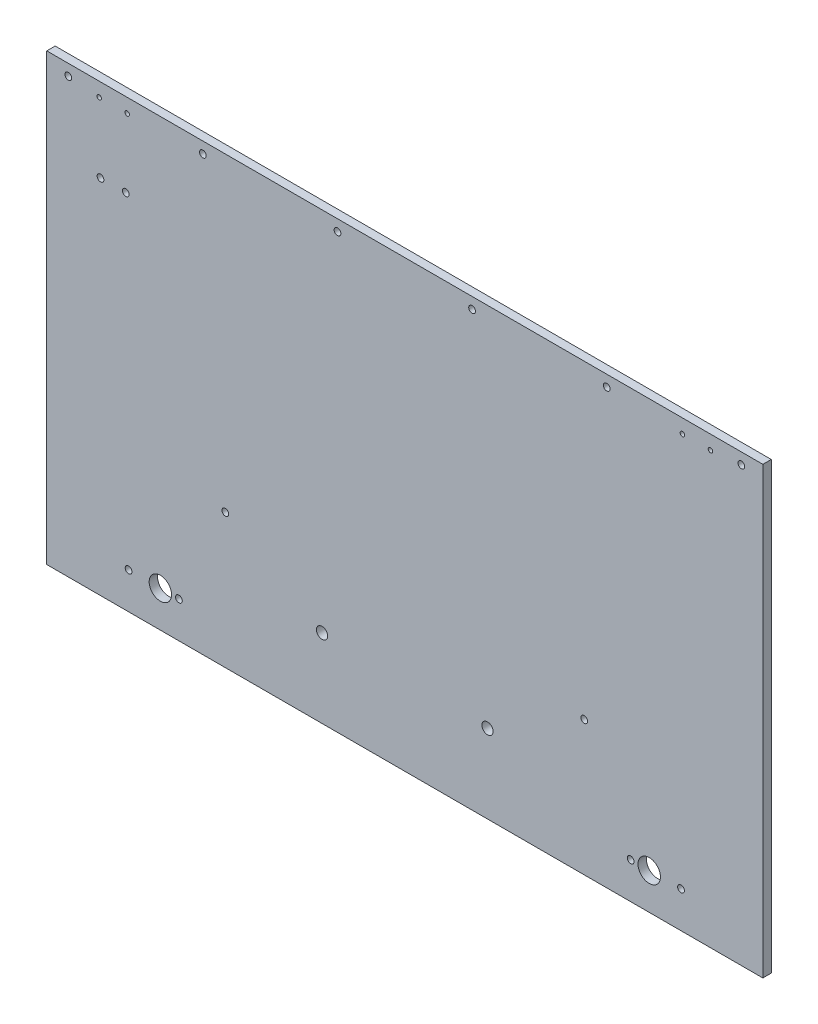
from build123d import *

# Parameters (mm, degrees)
SKETCH1_W           = 405.384
SKETCH1_H           = 251.841
BOSS_EXTRUDE1_DEPTH = 4.7625
SKETCH2_R           = 1.27
SKETCH2_R_2         = 6.35
SKETCH2_R_3         = 1.905
CUT_EXTRUDE1_DEPTH  = 478.265919738
SKETCH3_R           = 1.905
SKETCH3_R_2         = 3.175
CUT_EXTRUDE2_DEPTH  = 478.265919738
SKETCH4_W           = 1.211538462
SKETCH4_H           = 0.583333334
CUT_EXTRUDE3_DEPTH  = 1.016


with BuildPart() as part:
    # Sketch1 → Boss-Extrude1 (new body)
    with BuildSketch(Plane.XY):
        with Locations((202.692, 125.9205)):
            Rectangle(SKETCH1_W, SKETCH1_H)
    extrude(amount=BOSS_EXTRUDE1_DEPTH)

    # Sketch2 → Cut-Extrude1 (cut, through all)
    with BuildSketch(Plane.XY.offset(4.7625)):
        with Locations((29.6545, 243.9035)):
            Circle(SKETCH2_R)
        with Locations((45.5295, 243.9035)):
            Circle(SKETCH2_R)
        with Locations((359.8545, 243.9035)):
            Circle(SKETCH2_R)
        with Locations((375.7295, 243.9035)):
            Circle(SKETCH2_R)
        with Locations((64.3255, 20.5486)):
            Circle(SKETCH2_R_2)
        with Locations((341.0585, 20.5486)):
            Circle(SKETCH2_R_2)
        with Locations((46.3255, 20.5486)):
            Circle(SKETCH2_R_3)
        with Locations((74.8243, 20.5486)):
            Circle(SKETCH2_R_3)
        with Locations((330.5597, 20.5486)):
            Circle(SKETCH2_R_3)
        with Locations((359.0585, 20.5486)):
            Circle(SKETCH2_R_3)
    extrude(amount=-CUT_EXTRUDE1_DEPTH, mode=Mode.SUBTRACT)

    # Sketch3 → Cut-Extrude2 (cut, through all)
    with BuildSketch(Plane.XY.offset(4.7625)):
        with Locations((44.73575, 204.741046939)):
            Circle(SKETCH3_R)
        with Locations((30.44825, 204.741046939)):
            Circle(SKETCH3_R)
        with Locations((155.86075, 44.45)):
            Circle(SKETCH3_R_2)
        with Locations((249.52325, 44.45)):
            Circle(SKETCH3_R_2)
        with Locations((12.192, 245.491)):
            Circle(SKETCH3_R)
        with Locations((88.392, 245.491)):
            Circle(SKETCH3_R)
        with Locations((164.592, 245.491)):
            Circle(SKETCH3_R)
        with Locations((240.792, 245.491)):
            Circle(SKETCH3_R)
        with Locations((316.992, 245.491)):
            Circle(SKETCH3_R)
        with Locations((393.192, 245.491)):
            Circle(SKETCH3_R)
        with Locations((101.092, 76.2)):
            Circle(SKETCH3_R)
        with Locations((304.292, 76.2)):
            Circle(SKETCH3_R)
    extrude(amount=-CUT_EXTRUDE2_DEPTH, mode=Mode.SUBTRACT)

    # Sketch4 → Cut-Extrude3 (cut)
    # profile 1 of 9: a face of its own
    with BuildSketch(Plane.XY):
        Polygon((43.775641026, 9.85), (43.147435897, 9.85), (43.147435897, 6.978205128), (42.16025641, 6.978205128), (42.16025641, 6.35), (43.775641026, 6.35), align=None)
    # profile 2 of 9: a face of its own
    with BuildSketch(Plane.XY):
        with BuildLine():
            Line((38.480769231, 9.242828526), (38.94140625, 8.802524038))
            add(Edge.make_bspline(
                [(38.94140625, 8.802524038), (38.980481235, 8.842927638), (39.056806922, 8.921848526), (39.179796327, 9.026332827), (39.30770083, 9.113406355), (39.438032304, 9.186739125), (39.573135035, 9.242220593), (39.711446867, 9.282650872), (39.853850963, 9.307299686), (39.950224577, 9.310119946), (39.998697917, 9.311538462)],
                knots=[0, 0, 0, 0, 1.115251505, 2.178435587, 3.19620269, 4.182487026, 5.141301733, 6.088180966, 7.038406374, 8, 8, 8, 8], degree=3))
            add(Edge.make_bspline(
                [(39.998697917, 9.311538462), (40.039179046, 9.310417785), (40.119064094, 9.308206253), (40.236356279, 9.291993543), (40.348552316, 9.264423124), (40.456036269, 9.226425979), (40.558491863, 9.17725969), (40.656133908, 9.116962311), (40.748721672, 9.046078413), (40.835032124, 8.964974752), (40.913985892, 8.876362907), (40.983746573, 8.781814281), (41.042182334, 8.681545478), (41.090139613, 8.576571947), (41.127496479, 8.466407818), (41.154173975, 8.35112726), (41.169603525, 8.23059298), (41.171906489, 8.148654675), (41.173076923, 8.107011218)],
                knots=[0, 0, 0, 0, 1.035432265, 2.043311493, 3.022114605, 3.98653278, 4.95457646, 5.923598177, 6.917315552, 7.932509744, 8.948865224, 9.949768934, 10.933144597, 11.912367597, 12.897413939, 13.903909035, 14.934704909, 16, 16, 16, 16], degree=3))
            add(Edge.make_bspline(
                [(41.173076923, 8.107011218), (41.172739617, 8.077782926), (41.172074781, 8.020173362), (41.16479697, 7.934952828), (41.153077977, 7.852268764), (41.136117692, 7.772246412), (41.114908688, 7.694816425), (41.090025698, 7.61931082), (41.058810352, 7.546772912), (41.024160848, 7.476360221), (40.983863874, 7.409994047), (40.940416301, 7.346708391), (40.893304503, 7.286813475), (40.842223332, 7.23055415), (40.786453885, 7.178809624), (40.727437596, 7.130023877), (40.664178942, 7.085418182), (40.597991965, 7.04387311), (40.528304893, 7.007782552), (40.457008498, 6.975091479), (40.383021783, 6.948541467), (40.307245581, 6.927139735), (40.22995069, 6.908940759), (40.150381092, 6.89773509), (40.069226558, 6.889249168), (40.014379715, 6.888725212), (39.986778846, 6.888461538)],
                knots=[0, 0, 0, 0, 1.103660481, 2.175337485, 3.227646561, 4.255952547, 5.262355991, 6.258840057, 7.255597736, 8.242457506, 9.22035537, 10.185017736, 11.140346927, 12.096287581, 13.051739095, 14.01125915, 14.986044842, 15.97314143, 16.960198552, 17.947847494, 18.933482797, 19.925264591, 20.920966487, 21.929612487, 22.958107872, 24, 24, 24, 24], degree=3))
            add(Edge.make_bspline(
                [(39.986778846, 6.888461538), (39.939963029, 6.8898157), (39.847982123, 6.892476276), (39.712986917, 6.913281603), (39.584349935, 6.947505189), (39.481569602, 6.987921255), (39.401043925, 7.027832645), (39.339740919, 7.064748715), (39.276348831, 7.106043392), (39.211920552, 7.153275183), (39.145731391, 7.205877287), (39.07894974, 7.265001788), (39.009865975, 7.328701801), (38.964609885, 7.374165752), (38.94140625, 7.397475962)],
                knots=[0, 0, 0, 0, 1.404581149, 2.759636711, 4.088442092, 5.392261763, 6.066678138, 6.783632037, 7.538459478, 8.336747902, 9.180226004, 10.074962426, 11.012997595, 12, 12, 12, 12], degree=3))
            Line((38.94140625, 7.397475962), (38.494791667, 6.928425481))
            add(Edge.make_bspline(
                [(38.494791667, 6.928425481), (38.526186268, 6.898114979), (38.587461816, 6.838955361), (38.679894278, 6.754954225), (38.772210411, 6.679469865), (38.862180049, 6.609762532), (38.951276987, 6.547862968), (39.039491778, 6.493709355), (39.125825792, 6.445932068), (39.212071781, 6.405336849), (39.298766414, 6.370867291), (39.387965003, 6.341191265), (39.479940237, 6.316086414), (39.575253859, 6.295830096), (39.67301684, 6.279587264), (39.774144114, 6.268623446), (39.877994482, 6.261252837), (39.948437796, 6.260590526), (39.983974359, 6.26025641)],
                knots=[0, 0, 0, 0, 1.244526981, 2.429050516, 3.560637417, 4.644440555, 5.67424972, 6.652764056, 7.595344123, 8.486817594, 9.369275933, 10.254498637, 11.166417451, 12.086725134, 13.032340136, 13.991389299, 14.986715468, 16, 16, 16, 16], degree=3))
            add(Edge.make_bspline(
                [(39.983974359, 6.26025641), (40.049250623, 6.261920432), (40.176978127, 6.265176461), (40.364159453, 6.28930143), (40.541976689, 6.329746515), (40.71086243, 6.386947022), (40.870762974, 6.460017988), (41.021637415, 6.549599561), (41.163242575, 6.655453737), (41.294434564, 6.776339803), (41.413103962, 6.909848314), (41.517993967, 7.053199828), (41.604758983, 7.207098866), (41.676801845, 7.369271846), (41.733138416, 7.540458828), (41.772789812, 7.720844982), (41.797242538, 7.910256136), (41.799917701, 8.039628321), (41.801282051, 8.105608974)],
                knots=[0, 0, 0, 0, 1.078019885, 2.10938526, 3.111377082, 4.085535484, 5.04941344, 6.010039228, 6.978205633, 7.964457913, 8.951525778, 9.924444315, 10.892603023, 11.863865945, 12.85144698, 13.863884204, 14.910567087, 16, 16, 16, 16], degree=3))
            add(Edge.make_bspline(
                [(41.801282051, 8.105608974), (41.800705543, 8.148640994), (41.799563044, 8.233919938), (41.787555277, 8.359542733), (41.770815751, 8.482002487), (41.744260015, 8.600027663), (41.712249695, 8.715208277), (41.672440656, 8.826292451), (41.624896479, 8.933599451), (41.571149624, 9.037308917), (41.510346346, 9.13674144), (41.442422408, 9.231042737), (41.36912644, 9.320940799), (41.288697256, 9.405242959), (41.2023036, 9.484689407), (41.109555414, 9.558849608), (41.011010532, 9.628787103), (40.906402228, 9.692698373), (40.797762765, 9.750509514), (40.686462371, 9.801501409), (40.572774499, 9.844118891), (40.457179831, 9.879468521), (40.339189981, 9.905854519), (40.219647131, 9.925827869), (40.097534115, 9.936993099), (40.015545803, 9.938820919), (39.974158654, 9.93974359)],
                knots=[0, 0, 0, 0, 1.071919942, 2.124283339, 3.142214191, 4.149696895, 5.136002878, 6.119640489, 7.086990633, 8.058538607, 9.028339693, 9.988281803, 10.952401235, 11.916291999, 12.888973767, 13.874849856, 14.873389453, 15.898127285, 16.927174885, 17.938320013, 18.946391617, 19.950418109, 20.947802303, 21.956882652, 22.968648068, 24, 24, 24, 24], degree=3))
            add(Edge.make_bspline(
                [(39.974158654, 9.93974359), (39.938851172, 9.939214692), (39.868603307, 9.938162395), (39.763992448, 9.929390354), (39.660218217, 9.915613953), (39.557652159, 9.894828298), (39.455560616, 9.870153099), (39.355285185, 9.837844329), (39.255243968, 9.801830117), (39.157005961, 9.758782479), (39.060434039, 9.711792095), (38.967790552, 9.658479797), (38.877520024, 9.602126365), (38.791622796, 9.539396556), (38.708489827, 9.472565697), (38.628555828, 9.401321984), (38.552522265, 9.324477576), (38.504807823, 9.270182466), (38.480769231, 9.242828526)],
                knots=[0, 0, 0, 0, 0.996412454, 1.982464992, 2.961075852, 3.949442424, 4.934965278, 5.923860011, 6.921385422, 7.934793307, 8.949617135, 9.951082467, 10.950285876, 11.951772932, 12.951063433, 13.960125323, 14.972308753, 16, 16, 16, 16], degree=3))
        make_face()
    # profile 3 of 9: a face of its own
    with BuildSketch(Plane.XY):
        with BuildLine():
            Line((36.057692308, 9.382351763), (36.52744391, 8.952564103))
            add(Edge.make_bspline(
                [(36.52744391, 8.952564103), (36.547566055, 8.980948479), (36.586197766, 9.035442524), (36.64881574, 9.108411334), (36.711150962, 9.17065916), (36.77378093, 9.221925958), (36.837260772, 9.261900244), (36.901480295, 9.290202481), (36.966075423, 9.308194481), (37.009473377, 9.310434918), (37.030849359, 9.311538462)],
                knots=[0, 0, 0, 0, 1.299362458, 2.494594718, 3.587462134, 4.587049575, 5.512617175, 6.380583204, 7.202344345, 8, 8, 8, 8], degree=3))
            add(Edge.make_bspline(
                [(37.030849359, 9.311538462), (37.050788262, 9.310839206), (37.089285044, 9.309489126), (37.144165063, 9.296069437), (37.192888326, 9.272909025), (37.23540728, 9.242624837), (37.269088565, 9.206139412), (37.295980459, 9.167875583), (37.311122855, 9.125640968), (37.313115892, 9.096632532), (37.314102564, 9.082271635)],
                knots=[0, 0, 0, 0, 1.185010067, 2.2879431, 3.333075148, 4.379039566, 5.372662701, 6.27520591, 7.14612461, 8, 8, 8, 8], degree=3))
            add(Edge.make_bspline(
                [(37.314102564, 9.082271635), (37.313484267, 9.067703647), (37.312239103, 9.038365745), (37.300212509, 8.995367395), (37.282084998, 8.953353002), (37.264763421, 8.927776842), (37.255909455, 8.914703526)],
                knots=[0, 0, 0, 0, 0.967525499, 1.948461899, 2.951351359, 4, 4, 4, 4], degree=3))
            add(Edge.make_bspline(
                [(37.255909455, 8.914703526), (37.247860243, 8.904541774), (37.229332018, 8.881150764), (37.194002489, 8.84410305), (37.14963602, 8.798716357), (37.094525297, 8.746551401), (37.030958116, 8.685732126), (36.955988057, 8.618649361), (36.871773086, 8.543225631), (36.811915035, 8.490703276), (36.780548878, 8.46318109)],
                knots=[0, 0, 0, 0, 0.473873513, 1.090794244, 1.870441696, 2.795289791, 3.865433203, 5.087734844, 6.473946851, 8, 8, 8, 8], degree=3))
            add(Edge.make_bspline(
                [(36.780548878, 8.46318109), (36.751107228, 8.437700826), (36.695233092, 8.38934458), (36.615735292, 8.320710653), (36.545869966, 8.258962381), (36.484619336, 8.205026476), (36.432911902, 8.158337026), (36.390530284, 8.118670855), (36.356956864, 8.086800191), (36.337872341, 8.067550291), (36.329727564, 8.059334936)],
                knots=[0, 0, 0, 0, 1.543621617, 2.929473131, 4.163658386, 5.240097082, 6.164993805, 6.925417477, 7.541396219, 8, 8, 8, 8], degree=3))
            add(Edge.make_bspline(
                [(36.329727564, 8.059334936), (36.29882798, 8.025894968), (36.239428127, 7.961611605), (36.162229258, 7.861992611), (36.098692092, 7.764744159), (36.049538535, 7.668036363), (36.012415792, 7.570473922), (35.986243767, 7.469664122), (35.970569166, 7.364553564), (35.96882892, 7.292828439), (35.967948718, 7.256550481)],
                knots=[0, 0, 0, 0, 1.206664779, 2.319633467, 3.337109185, 4.282041471, 5.190008762, 6.099243693, 7.03861361, 8, 8, 8, 8], degree=3))
            add(Edge.make_bspline(
                [(35.967948718, 7.256550481), (35.968575223, 7.221202059), (35.96980445, 7.151847141), (35.984860117, 7.050356549), (36.006328616, 6.953225647), (36.039522681, 6.861511358), (36.07997941, 6.773708218), (36.130697764, 6.691183923), (36.190259516, 6.613103292), (36.258526428, 6.540862112), (36.33403774, 6.475308248), (36.415030799, 6.41695065), (36.502297595, 6.36876902), (36.595092535, 6.329094884), (36.693365947, 6.298537334), (36.797000759, 6.275952457), (36.906155487, 6.262397369), (36.980797062, 6.260980346), (37.018930288, 6.26025641)],
                knots=[0, 0, 0, 0, 1.043214005, 2.046824704, 3.02475056, 3.976699089, 4.921714032, 5.875962561, 6.831408892, 7.817874052, 8.806269674, 9.781291748, 10.760897367, 11.74438705, 12.757449933, 13.795994037, 14.874007457, 16, 16, 16, 16], degree=3))
            add(Edge.make_bspline(
                [(37.018930288, 6.26025641), (37.048864546, 6.260787464), (37.108151544, 6.261839255), (37.195531615, 6.270426251), (37.279906952, 6.284284751), (37.361182513, 6.30414812), (37.439724459, 6.329317702), (37.515536015, 6.360061383), (37.588093829, 6.396855678), (37.657946907, 6.43894395), (37.724755679, 6.487813977), (37.789364914, 6.542466629), (37.851132852, 6.603742487), (37.910356152, 6.671496636), (37.966655887, 6.74592094), (38.021874948, 6.825978902), (38.073559236, 6.91315629), (38.10548692, 6.974311933), (38.121794872, 7.005548878)],
                knots=[0, 0, 0, 0, 1.016823716, 2.013894106, 2.979844003, 3.91962641, 4.853723003, 5.779685073, 6.695824784, 7.614987388, 8.547259901, 9.504950863, 10.487499108, 11.500346958, 12.559593716, 13.656357062, 14.802919212, 16, 16, 16, 16], degree=3))
            Line((38.121794872, 7.005548878), (37.569310897, 7.337179487))
            add(Edge.make_bspline(
                [(37.569310897, 7.337179487), (37.548912087, 7.301721473), (37.509805823, 7.23374543), (37.443536604, 7.142411001), (37.375647172, 7.064198182), (37.304567985, 7.000489388), (37.231163338, 6.950432751), (37.15507867, 6.914658806), (37.076260527, 6.892514774), (37.022573188, 6.889810476), (36.995793269, 6.888461538)],
                knots=[0, 0, 0, 0, 1.283663364, 2.460892379, 3.537111102, 4.529833553, 5.449777664, 6.316464042, 7.160231139, 8, 8, 8, 8], degree=3))
            add(Edge.make_bspline(
                [(36.995793269, 6.888461538), (36.968554258, 6.889563154), (36.91570661, 6.891700449), (36.840273355, 6.911441996), (36.77111329, 6.942437673), (36.711331841, 6.98666423), (36.660712679, 7.037708399), (36.623352832, 7.094497371), (36.599883124, 7.155941668), (36.597401806, 7.198624918), (36.596153846, 7.220092147)],
                knots=[0, 0, 0, 0, 1.13588714, 2.203786484, 3.234766741, 4.283437687, 5.291419208, 6.222934724, 7.106237994, 8, 8, 8, 8], degree=3))
            add(Edge.make_bspline(
                [(36.596153846, 7.220092147), (36.597306286, 7.240063911), (36.599647359, 7.280634636), (36.616890974, 7.34095678), (36.643848006, 7.401251492), (36.675740074, 7.450706845), (36.708194248, 7.492114472), (36.739227757, 7.527992307), (36.777018363, 7.567631034), (36.821470244, 7.611080516), (36.871996075, 7.658723248), (36.928638418, 7.710554566), (36.992045887, 7.766117898), (37.036862411, 7.80396709), (37.060296474, 7.823758013)],
                knots=[0, 0, 0, 0, 0.916159276, 1.861089862, 2.860218735, 3.940849679, 4.552606315, 5.27541173, 6.11797699, 7.06649574, 8.129236253, 9.306560635, 10.591630461, 12, 12, 12, 12], degree=3))
            add(Edge.make_bspline(
                [(37.060296474, 7.823758013), (37.104845561, 7.861450812), (37.190348742, 7.933794702), (37.311175584, 8.04064435), (37.420051388, 8.140505137), (37.516035784, 8.23461156), (37.600351764, 8.321225691), (37.672428301, 8.401051045), (37.731473603, 8.474703364), (37.793606052, 8.561939606), (37.852644301, 8.668242962), (37.903670101, 8.796138223), (37.936773487, 8.924017255), (37.940482261, 9.009868194), (37.942307692, 9.052123397)],
                knots=[0, 0, 0, 0, 1.345494975, 2.582412109, 3.71882943, 4.751509156, 5.681369928, 6.505683931, 7.230279997, 7.856715994, 8.973648664, 10.023341002, 11.027102913, 12, 12, 12, 12], degree=3))
            add(Edge.make_bspline(
                [(37.942307692, 9.052123397), (37.941548498, 9.08208852), (37.940052803, 9.14112303), (37.926710976, 9.227924675), (37.906771107, 9.311680969), (37.877812692, 9.392086331), (37.840228166, 9.469040051), (37.79458322, 9.542918848), (37.740169073, 9.613042759), (37.678848003, 9.679365297), (37.611287883, 9.739976549), (37.53909131, 9.793472052), (37.462666922, 9.838655132), (37.382482245, 9.876137778), (37.298040408, 9.904828362), (37.209963489, 9.925165678), (37.11812516, 9.937261665), (37.05565871, 9.938905974), (37.023838141, 9.93974359)],
                knots=[0, 0, 0, 0, 1.010766082, 1.991317756, 2.957454644, 3.913069143, 4.869106762, 5.843196583, 6.838735724, 7.860187025, 8.887984031, 9.89767229, 10.887916223, 11.879572884, 12.879850636, 13.892031539, 14.926195476, 16, 16, 16, 16], degree=3))
            add(Edge.make_bspline(
                [(37.023838141, 9.93974359), (36.982600258, 9.93823502), (36.900450011, 9.935229789), (36.7789885, 9.911729864), (36.660349974, 9.874773756), (36.564748827, 9.830190278), (36.488680779, 9.787002242), (36.430381725, 9.747240139), (36.371059301, 9.701690512), (36.310235106, 9.650209824), (36.249039349, 9.59182811), (36.185731941, 9.527935192), (36.121175524, 9.457978887), (36.079224089, 9.408002427), (36.057692308, 9.382351763)],
                knots=[0, 0, 0, 0, 1.282922637, 2.555718331, 3.837320111, 5.142675274, 5.830281639, 6.55870424, 7.337177975, 8.157850921, 9.037902056, 9.96903443, 10.957596896, 12, 12, 12, 12], degree=3))
        make_face()
    # profile 4 of 9: a face of its own
    with BuildSketch(Plane.XY):
        Polygon((34.262119391, 9.85), (33.679487179, 9.85), (32.266025641, 6.35), (32.936999199, 6.35), (33.209034455, 7.067948718), (34.733974359, 7.067948718), (35.006009615, 6.35), (35.676282051, 6.35), align=None)
        Polygon((33.971153846, 8.911197917), (34.495592949, 7.696153846), (33.446714744, 7.696153846), align=None, mode=Mode.SUBTRACT)
    # profile 5 of 9: a face of its own
    with BuildSketch(Plane.XY):
        with BuildLine():
            Line((31.75, 9.85), (31.048878205, 9.85))
            add(Edge.make_bspline(
                [(31.048878205, 9.85), (31.003067817, 9.849794943), (30.914689975, 9.849399345), (30.787241855, 9.844602193), (30.669664725, 9.836005403), (30.561985597, 9.825381131), (30.464248747, 9.810486316), (30.376331777, 9.793410575), (30.298216444, 9.772607354), (30.229021881, 9.747914219), (30.166921996, 9.718801977), (30.108155475, 9.687795361), (30.054050449, 9.650790059), (30.001876074, 9.611774345), (29.954615248, 9.567021062), (29.909319558, 9.519508606), (29.867907401, 9.467352673), (29.830186887, 9.411184597), (29.795968569, 9.352042122), (29.766073157, 9.28981952), (29.741823673, 9.22441833), (29.721481371, 9.156261623), (29.705142236, 9.085352371), (29.694266388, 9.011254473), (29.686878965, 8.934485311), (29.686227126, 8.882236171), (29.685897436, 8.855809295)],
                knots=[0, 0, 0, 0, 1.698747864, 3.27724071, 4.728299578, 6.070144658, 7.288476769, 8.393259625, 9.389771311, 10.283485332, 11.113357557, 11.931608583, 12.74405601, 13.541433047, 14.344816069, 15.154114104, 15.974336324, 16.810834471, 17.661136416, 18.50621059, 19.367396281, 20.244825668, 21.142564693, 22.063065223, 23.020325768, 24, 24, 24, 24], degree=3))
            add(Edge.make_bspline(
                [(29.685897436, 8.855809295), (29.686374457, 8.826573871), (29.687311861, 8.769122669), (29.696501448, 8.684906257), (29.712200165, 8.604613532), (29.732717566, 8.527567372), (29.761327624, 8.455035358), (29.794013271, 8.385286853), (29.834226985, 8.320277391), (29.880177582, 8.259193782), (29.930360876, 8.201539387), (29.985968216, 8.148978868), (30.045939703, 8.101153923), (30.109928184, 8.057563341), (30.178173889, 8.018295054), (30.250627576, 7.982981357), (30.327784001, 7.952751692), (30.381513414, 7.936941821), (30.408754006, 7.928926282)],
                knots=[0, 0, 0, 0, 1.102006807, 2.165578795, 3.188629044, 4.184801286, 5.166646146, 6.124351954, 7.085497154, 8.042432466, 9.003981491, 9.963833307, 10.922997304, 11.89326795, 12.880200226, 13.889073926, 14.929769137, 16, 16, 16, 16], degree=3))
            add(Edge.make_bspline(
                [(30.408754006, 7.928926282), (30.426696227, 7.924462228), (30.465564856, 7.914791651), (30.529881759, 7.904973587), (30.604000238, 7.895946482), (30.688159965, 7.888188777), (30.782409461, 7.882915346), (30.886657467, 7.87879703), (31.000951227, 7.87580259), (31.080426588, 7.875696334), (31.121794872, 7.875641026)],
                knots=[0, 0, 0, 0, 0.618981996, 1.340914327, 2.176866532, 3.120127938, 4.170906482, 5.338178032, 6.614476169, 8, 8, 8, 8], degree=3))
            Line((31.121794872, 7.875641026), (31.121794872, 6.35))
            Line((31.121794872, 6.35), (31.75, 6.35))
            Line((31.75, 6.35), (31.75, 9.85))
        make_face()
        with BuildLine():
            Line((31.121794872, 8.503846154), (30.899539263, 8.503846154))
            add(Edge.make_bspline(
                [(30.899539263, 8.503846154), (30.859096346, 8.504102593), (30.784680778, 8.504574446), (30.68305539, 8.511397707), (30.601387274, 8.521818204), (30.536867946, 8.536763608), (30.485923825, 8.559445236), (30.441987711, 8.585683609), (30.404302583, 8.618861312), (30.37167281, 8.656772514), (30.345586289, 8.700334385), (30.327496646, 8.748837605), (30.315745969, 8.801263069), (30.314660685, 8.837747722), (30.314102564, 8.856510417)],
                knots=[0, 0, 0, 0, 1.8619151, 3.425951444, 4.686033666, 5.651700536, 6.461346321, 7.243864085, 7.999046032, 8.762387399, 9.539336099, 10.322741239, 11.137448474, 12, 12, 12, 12], degree=3))
            add(Edge.make_bspline(
                [(30.314102564, 8.856510417), (30.314654944, 8.872903138), (30.315726694, 8.904708959), (30.323600062, 8.950612649), (30.336147946, 8.993404356), (30.354329347, 9.03263718), (30.377833594, 9.068244457), (30.406490027, 9.100212159), (30.439930929, 9.129224904), (30.46574926, 9.144581793), (30.478866186, 9.152383814)],
                knots=[0, 0, 0, 0, 1.102301479, 2.1387299, 3.123554645, 4.094223062, 5.036071848, 5.982632524, 6.975082478, 8, 8, 8, 8], degree=3))
            add(Edge.make_bspline(
                [(30.478866186, 9.152383814), (30.489976979, 9.158002861), (30.513500806, 9.169899535), (30.553564164, 9.183730288), (30.599796666, 9.195398051), (30.652510436, 9.205082183), (30.711495182, 9.212598074), (30.77674038, 9.218345851), (30.848342046, 9.220657256), (30.89813672, 9.221405207), (30.924078526, 9.221794872)],
                knots=[0, 0, 0, 0, 0.656809284, 1.390599849, 2.23162475, 3.173112763, 4.218524733, 5.370385145, 6.63003504, 8, 8, 8, 8], degree=3))
            Line((30.924078526, 9.221794872), (31.121794872, 9.221794872))
            Line((31.121794872, 9.221794872), (31.121794872, 8.503846154))
        make_face(mode=Mode.SUBTRACT)
    # profile 6 of 9: a face of its own
    with BuildSketch(Plane.XY):
        with Locations((28.451923077, 7.628846154)):
            Rectangle(SKETCH4_W, SKETCH4_H)
    # profile 7 of 9: a face of its own
    with BuildSketch(Plane.XY):
        with BuildLine():
            Line((26.065304487, 9.93974359), (25.509314904, 9.657892628))
            Line((25.509314904, 9.657892628), (26.119290865, 8.458974359))
            add(Edge.make_bspline(
                [(26.119290865, 8.458974359), (26.083254058, 8.458041348), (26.012273656, 8.456203629), (25.907840397, 8.441350882), (25.808000257, 8.415674043), (25.711746553, 8.381639463), (25.620255895, 8.335930683), (25.532054775, 8.281557705), (25.449425001, 8.21524401), (25.370471942, 8.141771954), (25.298680331, 8.060375475), (25.236316625, 7.972912373), (25.181967756, 7.881510636), (25.139719132, 7.784125384), (25.105639986, 7.68237089), (25.081050382, 7.575840396), (25.067021324, 7.464225415), (25.065087185, 7.388400302), (25.064102564, 7.349799679)],
                knots=[0, 0, 0, 0, 1.013260694, 1.995783107, 2.958651975, 3.908806537, 4.861209129, 5.829647963, 6.817170299, 7.835534541, 8.860094905, 9.863329007, 10.853101798, 11.844815043, 12.84250023, 13.867713965, 14.914507806, 16, 16, 16, 16], degree=3))
            add(Edge.make_bspline(
                [(25.064102564, 7.349799679), (25.065025235, 7.312591021), (25.066848961, 7.239045459), (25.081924466, 7.131025732), (25.106287273, 7.027387122), (25.141106618, 6.928336607), (25.185364821, 6.833390025), (25.239489605, 6.742603092), (25.30392983, 6.656654229), (25.37702054, 6.576000127), (25.456921295, 6.502483317), (25.541141042, 6.437137297), (25.63039345, 6.383159006), (25.722991543, 6.337573073), (25.820640109, 6.303556092), (25.921877832, 6.277879165), (26.027472427, 6.263062463), (26.099147333, 6.261199246), (26.135416667, 6.26025641)],
                knots=[0, 0, 0, 0, 1.049934834, 2.075270938, 3.072134561, 4.05064612, 5.033440221, 6.024524368, 7.028587226, 8.060776465, 9.092543989, 10.090062252, 11.064205434, 12.031961459, 12.998029633, 13.977230324, 14.976426867, 16, 16, 16, 16], degree=3))
            add(Edge.make_bspline(
                [(26.135416667, 6.26025641), (26.173343368, 6.261030145), (26.247921094, 6.26255159), (26.357046971, 6.279587767), (26.46170808, 6.305233356), (26.561316207, 6.3418509), (26.656490786, 6.388476396), (26.746111308, 6.446170758), (26.830932701, 6.514297771), (26.910050646, 6.591324685), (26.981330018, 6.675697131), (27.044905261, 6.763297697), (27.098689998, 6.854263848), (27.142227489, 6.948498322), (27.17619645, 7.045700839), (27.199831918, 7.14605588), (27.215232606, 7.249297254), (27.217037986, 7.319362693), (27.217948718, 7.354707532)],
                knots=[0, 0, 0, 0, 1.063775006, 2.091769615, 3.092589432, 4.084662827, 5.064601646, 6.061867366, 7.070035304, 8.113879863, 9.156342271, 10.166834137, 11.149076039, 12.117706134, 13.076241869, 14.034148791, 15.008317125, 16, 16, 16, 16], degree=3))
            add(Edge.make_bspline(
                [(27.217948718, 7.354707532), (27.217467505, 7.382077976), (27.2165024, 7.436971218), (27.206803676, 7.519170865), (27.192058209, 7.601586278), (27.174966282, 7.671131014), (27.157366743, 7.729938366), (27.139652671, 7.779705439), (27.117699982, 7.834936007), (27.092604806, 7.895771109), (27.063577992, 7.962137558), (27.030771171, 8.033854458), (26.994102669, 8.111464902), (26.967952976, 8.16477126), (26.954326923, 8.192548077)],
                knots=[0, 0, 0, 0, 1.110454016, 2.227089276, 3.35462975, 4.507227546, 5.131400587, 5.845402449, 6.650387134, 7.543487832, 8.516250726, 9.590168902, 10.744287919, 12, 12, 12, 12], degree=3))
            Line((26.954326923, 8.192548077), (26.065304487, 9.93974359))
        make_face()
        with BuildLine():
            add(Edge.make_bspline(
                [(26.149439103, 7.875641026), (26.179582297, 7.874258421), (26.238568571, 7.871552845), (26.322438231, 7.843218739), (26.398908332, 7.798769578), (26.465193561, 7.736865525), (26.520635057, 7.662887751), (26.561375413, 7.578506218), (26.585883001, 7.484846975), (26.588429183, 7.419361994), (26.58974359, 7.385556891)],
                knots=[0, 0, 0, 0, 0.981744412, 1.921144944, 2.858899012, 3.85339082, 4.86292663, 5.863643845, 6.897155691, 8, 8, 8, 8], degree=3))
            add(Edge.make_bspline(
                [(26.58974359, 7.385556891), (26.588187291, 7.351740531), (26.585160185, 7.285965451), (26.559731079, 7.191414405), (26.518095742, 7.105116665), (26.459704838, 7.030158525), (26.391154756, 6.967937465), (26.315140845, 6.921922016), (26.232931045, 6.893653216), (26.176064519, 6.890204047), (26.147335737, 6.888461538)],
                knots=[0, 0, 0, 0, 1.098279937, 2.136227893, 3.159405121, 4.194678092, 5.206500211, 6.154139736, 7.067477469, 8, 8, 8, 8], degree=3))
            add(Edge.make_bspline(
                [(26.147335737, 6.888461538), (26.116994896, 6.890235082), (26.057491238, 6.89371331), (25.971653308, 6.920792611), (25.893239844, 6.96603715), (25.823907174, 7.028059004), (25.764351728, 7.102161771), (25.723145376, 7.188966412), (25.696540671, 7.284199894), (25.693750321, 7.351013724), (25.692307692, 7.385556891)],
                knots=[0, 0, 0, 0, 0.96921794, 1.900804717, 2.848419905, 3.844199796, 4.861108892, 5.867439427, 6.897452859, 8, 8, 8, 8], degree=3))
            add(Edge.make_bspline(
                [(25.692307692, 7.385556891), (25.69395111, 7.419342255), (25.697133779, 7.484771558), (25.7210394, 7.578869573), (25.763721271, 7.662925868), (25.820417175, 7.737170894), (25.888983591, 7.799047343), (25.968514181, 7.843569279), (26.056215147, 7.871502646), (26.11791138, 7.874241453), (26.149439103, 7.875641026)],
                knots=[0, 0, 0, 0, 1.083229974, 2.097801324, 3.086792542, 4.086858909, 5.079819718, 6.026392613, 6.991456328, 8, 8, 8, 8], degree=3))
        make_face(mode=Mode.SUBTRACT)
    # profile 8 of 9: a face of its own
    with BuildSketch(Plane.XY):
        with BuildLine():
            add(Edge.make_bspline(
                [(23.436798878, 9.93974359), (23.406391143, 9.939292178), (23.34660141, 9.938404583), (23.258542389, 9.928791201), (23.173717204, 9.914268063), (23.09179401, 9.894013349), (23.013362498, 9.867206957), (22.937851827, 9.835120165), (22.866160792, 9.796069956), (22.797375104, 9.751960738), (22.73152126, 9.702022851), (22.670182009, 9.64509108), (22.612237168, 9.58247543), (22.558941028, 9.513229263), (22.50911333, 9.437982447), (22.462917801, 9.35672305), (22.420708077, 9.269053361), (22.382011089, 9.174815174), (22.34740812, 9.072595899), (22.318262082, 8.961223037), (22.293264478, 8.840671153), (22.272164736, 8.710640176), (22.256216741, 8.570957264), (22.245467472, 8.421715214), (22.238090814, 8.263201744), (22.237488783, 8.154462806), (22.237179487, 8.098597756)],
                knots=[0, 0, 0, 0, 0.879237366, 1.728815576, 2.559023295, 3.367336655, 4.166867292, 4.954216142, 5.737608147, 6.525189134, 7.316157332, 8.124696809, 8.942788509, 9.781158001, 10.649253743, 11.551476218, 12.482711956, 13.461909668, 14.496590415, 15.601789533, 16.789733467, 18.056700938, 19.410929216, 20.8549011, 22.384193279, 24, 24, 24, 24], degree=3))
            add(Edge.make_bspline(
                [(22.237179487, 8.098597756), (22.237513753, 8.042033772), (22.238163224, 7.932130965), (22.245160822, 7.77216765), (22.257211017, 7.621842014), (22.272742177, 7.481169608), (22.294015618, 7.350224719), (22.318929775, 7.228668289), (22.348535875, 7.116544378), (22.384278654, 7.014105625), (22.422741408, 6.919701935), (22.465066594, 6.832203181), (22.510516488, 6.751372369), (22.558048608, 6.675990055), (22.61026884, 6.608278471), (22.664635477, 6.545935071), (22.723515739, 6.491334593), (22.784430541, 6.441663175), (22.849611437, 6.398737102), (22.918386235, 6.361194666), (22.991981069, 6.330743291), (23.069054431, 6.304258312), (23.150920052, 6.285244955), (23.236277098, 6.27015848), (23.326089234, 6.261820769), (23.387236953, 6.260786421), (23.418569712, 6.26025641)],
                knots=[0, 0, 0, 0, 1.643780988, 3.193836972, 4.651895693, 6.025988579, 7.305620092, 8.505800249, 9.631074763, 10.672816429, 11.65661981, 12.592235626, 13.49536222, 14.350718032, 15.179365177, 15.97804903, 16.751647189, 17.51006938, 18.259804725, 19.016521909, 19.783502495, 20.571750527, 21.382245291, 22.22305063, 23.089471752, 24, 24, 24, 24], degree=3))
            add(Edge.make_bspline(
                [(23.418569712, 6.26025641), (23.449901624, 6.260796645), (23.511280381, 6.261854957), (23.601335378, 6.270096486), (23.687144773, 6.28530607), (23.769658083, 6.304404282), (23.848301026, 6.33068469), (23.923450695, 6.362047148), (23.994529252, 6.399355338), (24.061733503, 6.442381425), (24.124833993, 6.491720504), (24.184811305, 6.546844838), (24.241532764, 6.607614701), (24.294135496, 6.674710765), (24.343480983, 6.747237439), (24.389054628, 6.826022941), (24.430829044, 6.910952561), (24.470110941, 7.002144684), (24.504241937, 7.10156257), (24.534616939, 7.210094009), (24.559499341, 7.3286437), (24.579511434, 7.457173557), (24.595489078, 7.595411285), (24.607374609, 7.743423606), (24.614411075, 7.901279462), (24.615053736, 8.009781655), (24.615384615, 8.065645032)],
                knots=[0, 0, 0, 0, 0.917216111, 1.796812873, 2.643793957, 3.46689424, 4.273913431, 5.068098542, 5.848489301, 6.620921603, 7.401012384, 8.190319798, 9.003608147, 9.831726257, 10.68377682, 11.569763213, 12.493818149, 13.453288342, 14.474581811, 15.568529029, 16.750744269, 18.018426408, 19.375425659, 20.823733699, 22.36466933, 24, 24, 24, 24], degree=3))
            add(Edge.make_bspline(
                [(24.615384615, 8.065645032), (24.614785258, 8.143262797), (24.613628789, 8.293027275), (24.598973169, 8.509393402), (24.577462435, 8.709386406), (24.545868263, 8.892671749), (24.506802506, 9.059928265), (24.45677677, 9.210054156), (24.399826109, 9.345126752), (24.351296829, 9.425144571), (24.327924679, 9.463681891)],
                knots=[0, 0, 0, 0, 1.288568992, 2.486310467, 3.599230591, 4.627010532, 5.572937695, 6.447898582, 7.252493626, 8, 8, 8, 8], degree=3))
            add(Edge.make_bspline(
                [(24.327924679, 9.463681891), (24.300748658, 9.501540942), (24.24761418, 9.575562848), (24.15470706, 9.672739774), (24.054890456, 9.755850239), (23.946114192, 9.82301338), (23.830098609, 9.875978238), (23.705847656, 9.913386721), (23.573820169, 9.935182647), (23.483154692, 9.938200572), (23.436798878, 9.93974359)],
                knots=[0, 0, 0, 0, 1.058512271, 2.069600068, 3.047294572, 4.004278952, 4.967380941, 5.939006123, 6.946246673, 8, 8, 8, 8], degree=3))
        make_face()
        with BuildLine():
            add(Edge.make_bspline(
                [(23.421374199, 9.311538462), (23.448863044, 9.310235545), (23.502755772, 9.307681137), (23.580956689, 9.285997815), (23.654695271, 9.252506756), (23.71078624, 9.212205503), (23.752769773, 9.173571918), (23.782103969, 9.138609781), (23.810392177, 9.099594555), (23.835377747, 9.054765685), (23.858970647, 9.005733924), (23.882028022, 8.952276698), (23.900929015, 8.893080981), (23.91949874, 8.829154885), (23.935767551, 8.758731022), (23.949397248, 8.681233756), (23.961574185, 8.596159114), (23.970067743, 8.503451372), (23.977986289, 8.403207526), (23.983662677, 8.295204271), (23.986035832, 8.179470744), (23.986790186, 8.099766781), (23.987179487, 8.058633814)],
                knots=[0, 0, 0, 0, 1.076674018, 2.110852608, 3.161083442, 4.239746716, 4.804137807, 5.395870207, 6.026861976, 6.692161227, 7.405688833, 8.16177676, 8.973626916, 9.841385931, 10.773283133, 11.807421078, 12.927755683, 14.143907515, 15.458935494, 16.872852025, 18.386167141, 20, 20, 20, 20], degree=3))
            add(Edge.make_bspline(
                [(23.987179487, 8.058633814), (23.986538745, 8.005344067), (23.985310075, 7.903157026), (23.978874876, 7.756208503), (23.965976054, 7.622473515), (23.949932523, 7.501045689), (23.927398728, 7.392712518), (23.901472139, 7.29644907), (23.869455107, 7.21348247), (23.832453257, 7.142612834), (23.791472041, 7.082324181), (23.746985128, 7.031078555), (23.700507138, 6.986702261), (23.650587343, 6.950655944), (23.597344835, 6.923031708), (23.541224092, 6.903161936), (23.48218945, 6.890998822), (23.441763136, 6.889312189), (23.421374199, 6.888461538)],
                knots=[0, 0, 0, 0, 1.771748488, 3.397459088, 4.888034009, 6.237357457, 7.467047327, 8.564189669, 9.548206622, 10.417051504, 11.216568818, 11.965764335, 12.669334354, 13.348544111, 14.005342236, 14.656555988, 15.322436492, 16, 16, 16, 16], degree=3))
            add(Edge.make_bspline(
                [(23.421374199, 6.888461538), (23.401684945, 6.889043617), (23.363135835, 6.890183253), (23.3069226, 6.901881469), (23.25376337, 6.920900227), (23.20381865, 6.947803595), (23.156909795, 6.982015344), (23.113266066, 7.023685815), (23.073216616, 7.073230366), (23.049883624, 7.109999749), (23.037860577, 7.128946314)],
                knots=[0, 0, 0, 0, 0.992283464, 1.942767638, 2.88273346, 3.832339453, 4.79467288, 5.803907806, 6.868395428, 8, 8, 8, 8], degree=3))
            add(Edge.make_bspline(
                [(23.037860577, 7.128946314), (23.023705464, 7.154836189), (22.99402334, 7.209125158), (22.959675134, 7.300735767), (22.930762729, 7.404057394), (22.905878245, 7.519411585), (22.888858776, 7.64725331), (22.87420163, 7.786771915), (22.867132124, 7.938669958), (22.86598223, 8.04390547), (22.865384615, 8.098597756)],
                knots=[0, 0, 0, 0, 0.710965849, 1.490837728, 2.352621235, 3.297892224, 4.334225155, 5.461620853, 6.680770821, 8, 8, 8, 8], degree=3))
            add(Edge.make_bspline(
                [(22.865384615, 8.098597756), (22.865615461, 8.153764798), (22.8660598, 8.259951935), (22.874212127, 8.412396063), (22.885564865, 8.551628473), (22.902170643, 8.677338316), (22.923536996, 8.789830761), (22.949871106, 8.889098454), (22.980917063, 8.975337033), (23.017733867, 9.048460505), (23.058510766, 9.110605426), (23.101796689, 9.163920947), (23.147774667, 9.209440394), (23.196367809, 9.247335064), (23.24870082, 9.276289435), (23.303774073, 9.296733616), (23.361700471, 9.309101659), (23.401214475, 9.310715231), (23.421374199, 9.311538462)],
                knots=[0, 0, 0, 0, 1.793836731, 3.452829483, 4.963243077, 6.335886805, 7.574563692, 8.684454726, 9.672768357, 10.54971625, 11.340229787, 12.085688095, 12.778991901, 13.440269426, 14.083255152, 14.715733572, 15.344777694, 16, 16, 16, 16], degree=3))
        make_face(mode=Mode.SUBTRACT)
    # profile 9 of 9: a face of its own
    with BuildSketch(Plane.XY):
        Polygon((21.278745994, 9.85), (20.307692308, 9.85), (20.307692308, 6.35), (20.935897436, 6.35), (20.935897436, 9.266666667), (21.653846154, 9.266666667), align=None)
    extrude(amount=CUT_EXTRUDE3_DEPTH, mode=Mode.SUBTRACT)


solid = part.part
